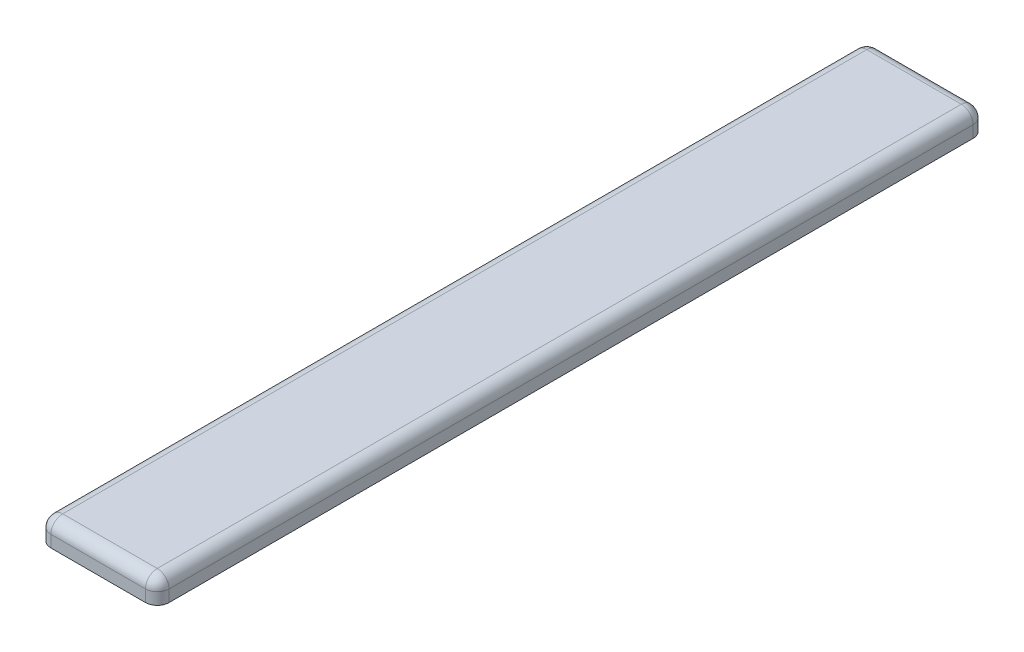
from build123d import *

# Parameters (mm, degrees)
SKETCH1_W           = 100
SKETCH1_H           = 700
BOSS_EXTRUDE1_DEPTH = 20
FILLET1_R           = 10


with BuildPart() as part:
    # Sketch1 → Boss-Extrude1 (new body)
    with BuildSketch(Plane(origin=(0, 0, 0), x_dir=(1, 0, 0), z_dir=(0, 1, 0))):
        with Locations((50, 350)):
            Rectangle(SKETCH1_W, SKETCH1_H)
    extrude(amount=BOSS_EXTRUDE1_DEPTH)

    # Fillet1
    fillet1_edges = [part.edges().sort_by_distance(p)[0] for p in [
        (100, 20, -350),
        (50, 20, -700),
        (0, 20, -350),
        (50, 20, 0),
        (0, 10, -700),
        (100, 10, -700),
        (100, 10, 0),
        (0, 10, 0),
    ]]
    fillet(fillet1_edges, radius=FILLET1_R)


solid = part.part
